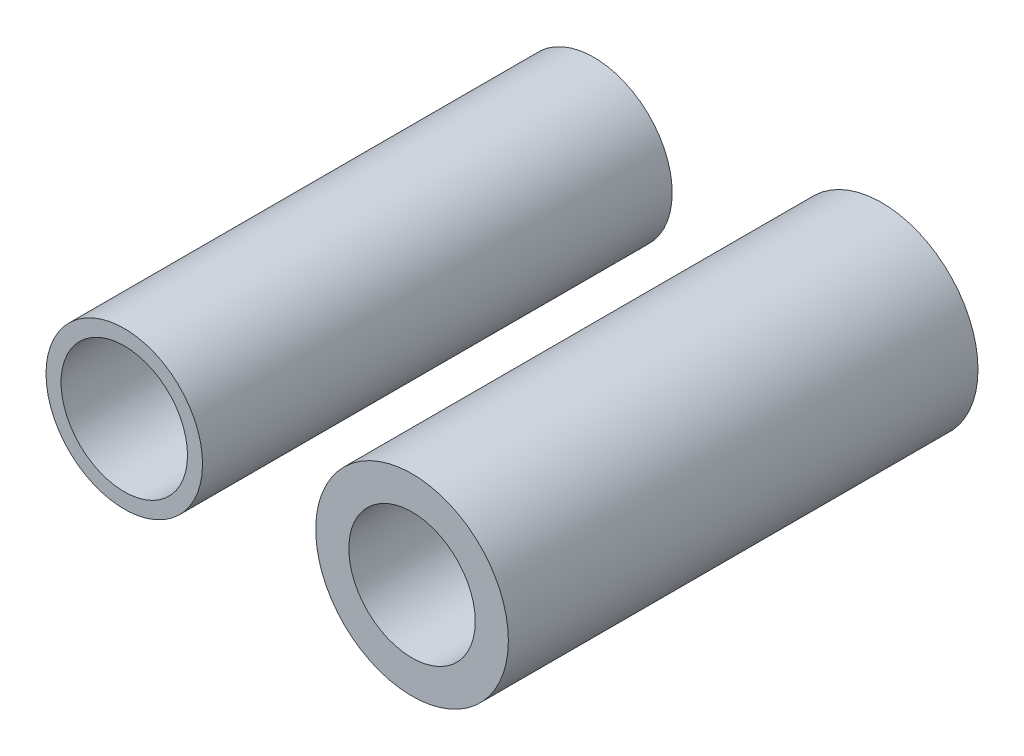
from build123d import *

# Parameters (mm, degrees)
SKETCH1_R           = 4.064
BOSS_EXTRUDE1_DEPTH = 19.812
SKETCH2_R           = 3.302
BOSS_EXTRUDE2_DEPTH = 19.812
SKETCH3_R           = 2.667
CUT_EXTRUDE1_DEPTH  = 19.812
SKETCH5_R           = 2.667
CUT_EXTRUDE2_DEPTH  = 19.812


with BuildPart() as part:
    # Sketch1 → Boss-Extrude1 (new body)
    with BuildSketch(Plane.XY):
        Circle(SKETCH1_R)
    extrude(amount=BOSS_EXTRUDE1_DEPTH)

    # Sketch3 → Cut-Extrude1 (cut)
    with BuildSketch(Plane.XY.offset(19.812)):
        Circle(SKETCH3_R)
    extrude(amount=-CUT_EXTRUDE1_DEPTH, mode=Mode.SUBTRACT)


with BuildPart() as body_2:
    # Sketch2 → Boss-Extrude2 (new body)
    with BuildSketch(Plane(origin=(0, 0, 0), x_dir=(-1, 0, 0), z_dir=(0, 0, -1))):
        with Locations((12.139551254, 0)):
            Circle(SKETCH2_R)
    extrude(amount=-BOSS_EXTRUDE2_DEPTH)

    # Sketch5 → Cut-Extrude2 (cut)
    with BuildSketch(Plane.XY.offset(19.812)):
        with Locations((-12.139551254, 0)):
            Circle(SKETCH5_R)
    extrude(amount=-CUT_EXTRUDE2_DEPTH, mode=Mode.SUBTRACT)


solid = Compound([part.part, body_2.part])
